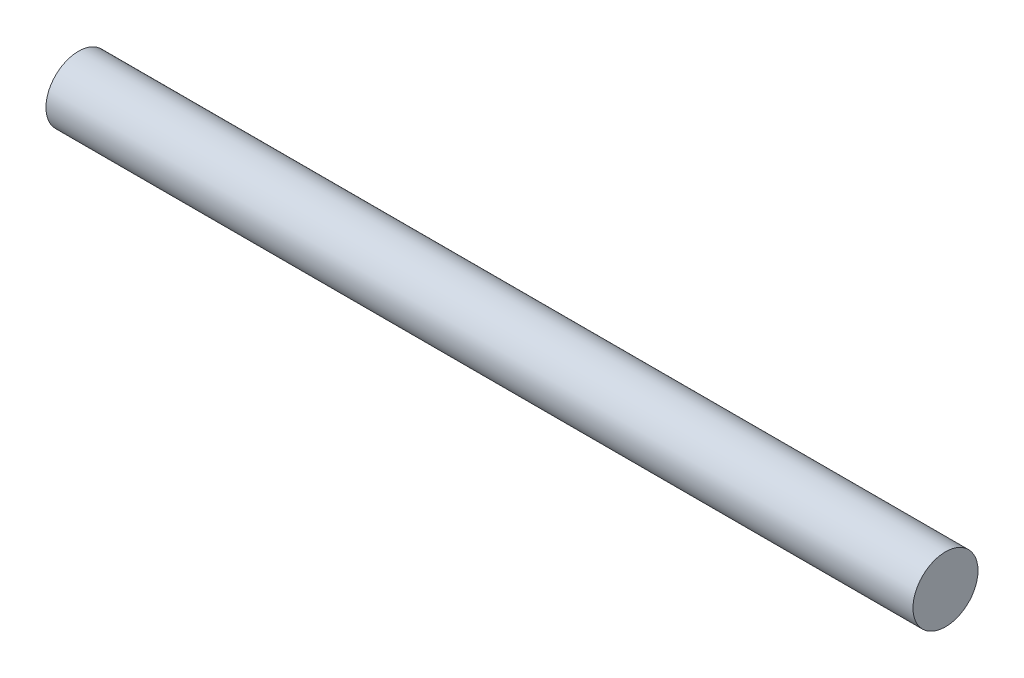
from build123d import *

# Parameters (mm, degrees)
SKETCH1_R           = 0.375
BOSS_EXTRUDE1_DEPTH = 5


with BuildPart() as part:
    # Sketch1 → Boss-Extrude1 (new body, symmetric)
    with BuildSketch(Plane(origin=(0, 0, 0), x_dir=(0, 0, -1), z_dir=(1, 0, 0))):
        Circle(SKETCH1_R)
    extrude(amount=BOSS_EXTRUDE1_DEPTH, both=True)


solid = part.part
